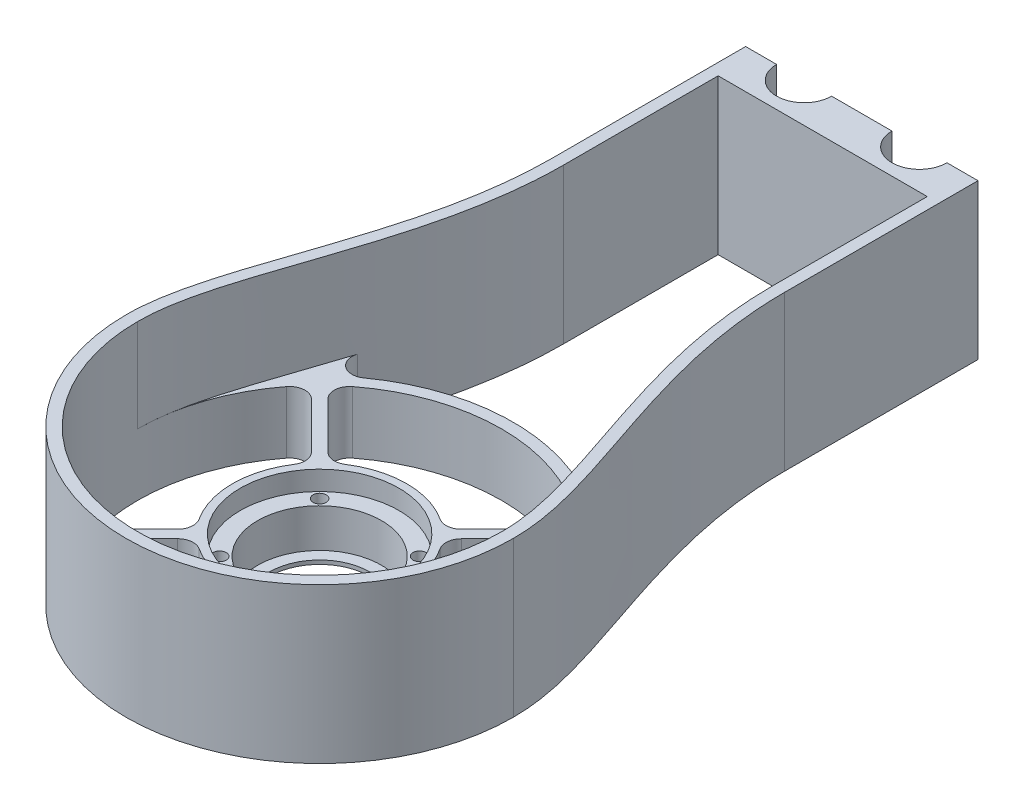
from build123d import *

# Parameters (mm, degrees)
EXTRUDE_1_DEPTH            = 40
CUT_EXTRUDE_1_DEPTH        = 41.0000001
SKETCH_3_R                 = 22.5
SKETCH_3_R_2               = 13
EXTRUDE_2_DEPTH            = 16
SKETCH_4_R                 = 20.5
CUT_EXTRUDE_2_DEPTH        = 5
SKETCH_5_R                 = 16
CUT_EXTRUDE_3_DEPTH        = 10
SKETCH_7_W                 = 1.7
SKETCH_7_H                 = 11
HOLE_WIZARD_M31_AT_2_COUNT = 2
HOLE_WIZARD_M31_AT_2_PITCH = 25.809397513
HOLE_WIZARD_M31_AT_3_COUNT = 2
HOLE_WIZARD_M31_AT_3_PITCH = 36.5
HOLE_WIZARD_M31_AT_4_COUNT = 2
HOLE_WIZARD_M31_AT_4_PITCH = 25.809397513
EXTRUDE_3_DEPTH            = 16
EXTRUDE_4_DEPTH            = 16
FILLET_1_R                 = 4
FILLET_2_R                 = 4
EXTRUDE_5_DEPTH            = 40


with BuildPart() as part:
    # Эскиз1 → Бобышка-Вытянуть1 (new body)
    with BuildSketch(Plane(origin=(0, 0, 0), x_dir=(1, 0, 0), z_dir=(0, 1, 0))):
        with BuildLine():
            Line((0, 0), (8, 0))
            ThreePointArc((8, 0), (15.1, -7.1), (22.2, 0))
            Line((22.2, 0), (37.8, 0))
            ThreePointArc((37.8, 0), (44.9, -7.1), (52, 0))
            Line((52, 0), (60, 0))
            Line((60, 0), (60, -50))
            add(Edge.make_bspline(
                [(60, -50), (60, -86.116353651), (80.160728995, -116.642608399), (80, -140)],
                knots=[0, 0, 0, 0, 1, 1, 1, 1], degree=3))
            ThreePointArc((80, -140), (30, -190), (-20, -140))
            add(Edge.make_bspline(
                [(0, -50), (0, -86.116353651), (-20.160728995, -116.642608399), (-20, -140)],
                knots=[0, 0, 0, 0, 1, 1, 1, 1], degree=3))
            Line((0, -50), (0, 0))
        make_face()
    extrude(amount=EXTRUDE_1_DEPTH)

    # Эскиз2 → Вырез-Вытянуть1 (cut, through all)
    with BuildSketch(Plane.XZ):
        with BuildLine():
            Line((3, 50), (3, 3))
            Line((3, 3), (5.455830777, 3))
            ThreePointArc((5.455830777, 3), (15.1, 10.1), (24.744169223, 3))
            Line((24.744169223, 3), (35.255830777, 3))
            ThreePointArc((35.255830777, 3), (44.9, 10.1), (54.544169223, 3))
            Line((54.544169223, 3), (57, 3))
            Line((57, 3), (57, 50))
            add(Edge.make_bspline(
                [(57, 50), (57, 51.157609129), (57.040606582, 53.481410198), (57.273704219, 58.056259254), (57.830047707, 63.685631551), (58.858223783, 70.278683586), (60.625819875, 78.854483127), (63.422404864, 89.162496802), (67.223313935, 100.856350391), (70.98262402, 111.850711206), (73.680271867, 120.398992166), (75.344252207, 126.83842419), (76.290135947, 131.459638595), (76.783312256, 135.122784785), (76.977813987, 137.947550146), (77.004716082, 139.304329707), (76.999998901, 139.989837839)],
                knots=[0, 0, 0, 0, 0.031254674, 0.062509349, 0.125018697, 0.187528046, 0.250037394, 0.375056092, 0.500074789, 0.625093486, 0.750112183, 0.812621532, 0.87513088, 0.937640229, 0.968894903, 1.000149578, 1.000149578, 1.000149578, 1.000149578], degree=3))
            ThreePointArc((76.999998901, 139.989837839), (30, 187), (-16.999998901, 139.989837839))
            add(Edge.make_bspline(
                [(-16.999998901, 139.989837839), (-17.004716082, 139.304329707), (-16.977813987, 137.947550146), (-16.783312256, 135.122784785), (-16.290135947, 131.459638595), (-15.344252207, 126.83842419), (-13.680271867, 120.398992166), (-10.98262402, 111.850711206), (-7.223313935, 100.856350391), (-3.422404864, 89.162496802), (-0.625819875, 78.854483127), (1.141776217, 70.278683586), (2.169952293, 63.685631551), (2.726295781, 58.056259254), (2.959393418, 53.481410198), (3, 51.157609129), (3, 50)],
                knots=[-0.000149578, -0.000149578, -0.000149578, -0.000149578, 0.031105097, 0.062359771, 0.12486912, 0.187378468, 0.249887817, 0.374906514, 0.499925211, 0.624943908, 0.749962606, 0.812471954, 0.874981303, 0.937490651, 0.968745326, 1, 1, 1, 1], degree=3))
        make_face()
    extrude(amount=-CUT_EXTRUDE_1_DEPTH, mode=Mode.SUBTRACT)

    # Эскиз9 → Бобышка-Вытянуть3 (add)
    with BuildSketch(Plane.XZ):
        with BuildLine():
            ThreePointArc((-10.590299222, 110.803637057), (30, 90), (70.590299222, 110.803637057))
            add(Edge.make_bspline(
                [(70.590299222, 110.803637057), (70.692686494, 111.112669843), (71.968099867, 114.973477738), (73.680271867, 120.398992166), (75.344252207, 126.83842419), (76.290135947, 131.459638595), (76.783312256, 135.122784785), (76.977813987, 137.947550146), (77.004716082, 139.304329707), (76.999998901, 139.989837839)],
                knots=[0.614251021, 0.614251021, 0.614251021, 0.614251021, 0.625093486, 0.750112183, 0.812621532, 0.87513088, 0.937640229, 0.968894903, 1.000149578, 1.000149578, 1.000149578, 1.000149578], degree=3))
            ThreePointArc((76.999998901, 139.989837839), (30, 93), (-16.999998901, 139.989837839))
            add(Edge.make_bspline(
                [(-16.999998901, 139.989837839), (-17.004716082, 139.304329707), (-16.977813987, 137.947550146), (-16.783312256, 135.122784785), (-16.290135947, 131.459638595), (-15.344252207, 126.83842419), (-13.680271867, 120.398992166), (-11.968099867, 114.973477738), (-10.692686494, 111.112669843), (-10.590299222, 110.803637057)],
                knots=[-0.000149578, -0.000149578, -0.000149578, -0.000149578, 0.031105097, 0.062359771, 0.12486912, 0.187378468, 0.249887817, 0.374906514, 0.385748979, 0.385748979, 0.385748979, 0.385748979], degree=3))
        make_face()
    extrude(amount=-EXTRUDE_3_DEPTH)



with BuildPart() as body_2:
    # Эскиз3 → Бобышка-Вытянуть2 (new body)
    with BuildSketch(Plane.XZ):
        with Locations((30, 140)):
            Circle(SKETCH_3_R)
        with Locations((30, 140)):
            Circle(SKETCH_3_R_2, mode=Mode.SUBTRACT)
    extrude(amount=-EXTRUDE_2_DEPTH)

    # Эскиз4 → Вырез-Вытянуть2 (cut)
    with BuildSketch(Plane(origin=(0, 16, 0), x_dir=(1, 0, 0), z_dir=(0, 1, 0))):
        with Locations((30, -140)):
            Circle(SKETCH_4_R)
    extrude(amount=-CUT_EXTRUDE_2_DEPTH, mode=Mode.SUBTRACT)

    # Эскиз5 → Вырез-Вытянуть3 (cut)
    with BuildSketch(Plane(origin=(0, 11, 0), x_dir=(1, 0, 0), z_dir=(0, 1, 0))):
        with Locations((30, -140)):
            Circle(SKETCH_5_R)
    extrude(amount=-CUT_EXTRUDE_3_DEPTH, mode=Mode.SUBTRACT)

    # Эскиз7 → Отверстие с зазором M31 (revolve, cut)
    with BuildSketch(Plane(origin=(17.095301243, 11, 127.095301243), x_dir=(0, 0, 1), z_dir=(1, 0, 0))):
        with Locations((0.85, 5.5)):
            Rectangle(SKETCH_7_W, SKETCH_7_H)
    hole_wizard_m31 = revolve(axis=Axis((17.095301243, 17.35, 127.095301243), (0, -1, 0)), mode=Mode.SUBTRACT)

    # Отверстие с зазором M31 at 2: Отверстие с зазором M31 ×2
    with Locations(*[(i * HOLE_WIZARD_M31_AT_2_PITCH, 0, 0) for i in range(1, HOLE_WIZARD_M31_AT_2_COUNT)]):
        add(hole_wizard_m31, mode=Mode.SUBTRACT)

    # Отверстие с зазором M31 at 3: Отверстие с зазором M31 ×2
    with Locations(*[Vector(0.707106781, 0, 0.707106781) * (i * HOLE_WIZARD_M31_AT_3_PITCH) for i in range(1, HOLE_WIZARD_M31_AT_3_COUNT)]):
        add(hole_wizard_m31, mode=Mode.SUBTRACT)

    # Отверстие с зазором M31 at 4: Отверстие с зазором M31 ×2
    with Locations(*[(0, 0, i * HOLE_WIZARD_M31_AT_4_PITCH) for i in range(1, HOLE_WIZARD_M31_AT_4_COUNT)]):
        add(hole_wizard_m31, mode=Mode.SUBTRACT)


with BuildPart() as part_1:
    add(part.part)

    add(body_2.part)  # Бобышка-Вытянуть4 merges body 2
    # Эскиз10 → Бобышка-Вытянуть4 (add)
    with BuildSketch(Plane.XZ):
        with BuildLine():
            Line((13.061629364, 154.810185691), (-4.284701087, 172.149016647))
            ThreePointArc((-4.284701087, 172.149016647), (-3.241203672, 173.226832206), (-2.163839457, 174.270795605))
            Line((-2.163839457, 174.270795605), (15.182490994, 156.931964648))
            ThreePointArc((15.182490994, 156.931964648), (14.086657817, 155.906462226), (13.061629364, 154.810185691))
        make_face()
        with BuildLine():
            Line((15.189814309, 123.061629364), (-2.149016647, 105.715298913))
            ThreePointArc((-2.149016647, 105.715298913), (-3.226832206, 106.758796328), (-4.270795605, 107.836160543))
            Line((-4.270795605, 107.836160543), (13.068035352, 125.182490994))
            ThreePointArc((13.068035352, 125.182490994), (14.093537774, 124.086657817), (15.189814309, 123.061629364))
        make_face()
        with BuildLine():
            Line((44.810185691, 156.938370636), (62.149016647, 174.284701087))
            ThreePointArc((62.149016647, 174.284701087), (63.226832206, 173.241203672), (64.270795605, 172.163839457))
            Line((64.270795605, 172.163839457), (46.931964648, 154.817509006))
            ThreePointArc((46.931964648, 154.817509006), (45.906462226, 155.913342183), (44.810185691, 156.938370636))
        make_face()
        with BuildLine():
            Line((46.938370636, 125.189814309), (64.284701087, 107.850983353))
            ThreePointArc((64.284701087, 107.850983353), (63.241203672, 106.773167794), (62.163839457, 105.729204395))
            Line((62.163839457, 105.729204395), (44.817509006, 123.068035352))
            ThreePointArc((44.817509006, 123.068035352), (45.913342183, 124.093537774), (46.938370636, 125.189814309))
        make_face()
    extrude(amount=-EXTRUDE_4_DEPTH)

    # Скругление1
    fillet_1_edges = [part_1.edges().sort_by_distance(p)[0] for p in [
        (70.590299222, 8, 110.803637057),
        (-10.590299222, 8, 110.803637057),
    ]]
    fillet(fillet_1_edges, radius=FILLET_1_R)

    # Скругление2
    fillet_2_edges = [part_1.edges().sort_by_distance(p)[0] for p in [
        (-4.284701087, 8, 172.149016647),
        (-2.163839457, 8, 174.270795605),
        (15.182490994, 8, 156.931964648),
        (13.061629364, 8, 154.810185691),
        (62.149016647, 8, 174.284701087),
        (64.270795605, 8, 172.163839457),
        (46.931964648, 8, 154.817509006),
        (44.810185691, 8, 156.938370636),
        (64.284701087, 8, 107.850983353),
        (62.163839457, 8, 105.729204395),
        (44.817509006, 8, 123.068035352),
        (46.938370636, 8, 125.189814309),
        (-2.149016647, 8, 105.715298913),
        (-4.270795605, 8, 107.836160543),
        (13.068035352, 8, 125.182490994),
        (15.189814309, 8, 123.061629364),
    ]]
    fillet(fillet_2_edges, radius=FILLET_2_R)

    # Эскиз11 → Бобышка-Вытянуть5 (add, through all)
    with BuildSketch(Plane(origin=(0, 40, 0), x_dir=(1, 0, 0), z_dir=(0, 1, 0))):
        with BuildLine():
            ThreePointArc((24.744169223, -3), (21.087904475, -8.133572401), (15.1, -10.1))
            Line((15.1, -10.1), (44.9, -10.1))
            ThreePointArc((44.9, -10.1), (38.912095525, -8.133572401), (35.255830777, -3))
            Line((35.255830777, -3), (24.744169223, -3))
        make_face()
        with BuildLine():
            ThreePointArc((54.544169223, -3), (50.887904475, -8.133572401), (44.9, -10.1))
            Line((44.9, -10.1), (57, -10.1))
            Line((57, -10.1), (57, -3))
            Line((57, -3), (54.544169223, -3))
        make_face()
        with BuildLine():
            Line((3, -3), (3, -10.1))
            Line((3, -10.1), (15.1, -10.1))
            ThreePointArc((15.1, -10.1), (9.112095525, -8.133572401), (5.455830777, -3))
            Line((5.455830777, -3), (3, -3))
        make_face()
    extrude(amount=-EXTRUDE_5_DEPTH)


solid = part_1.part
